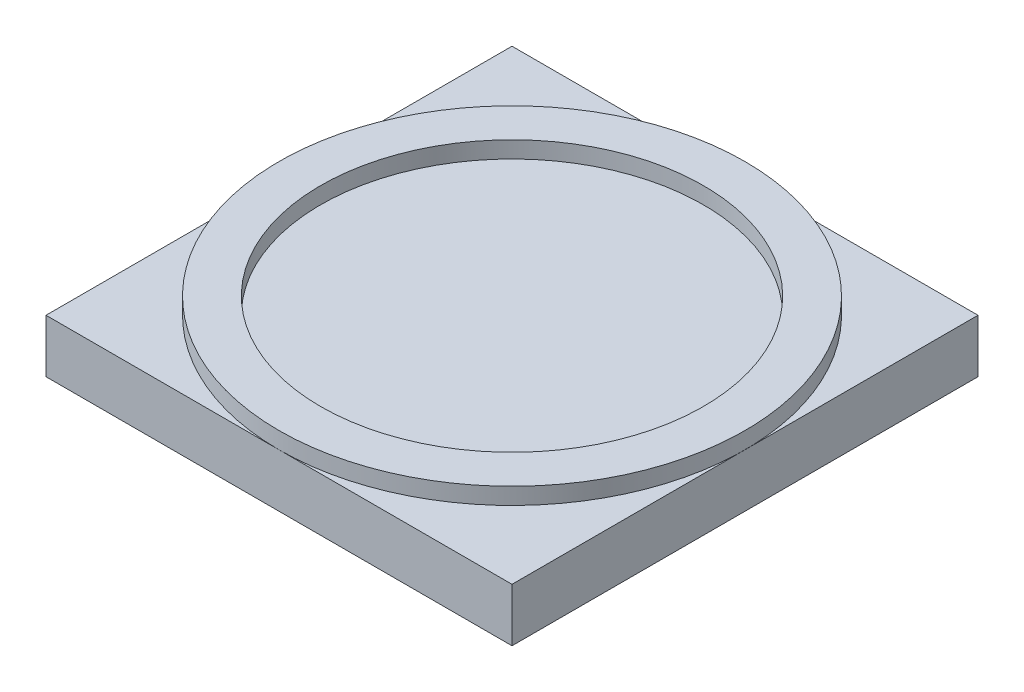
from build123d import *

# Parameters (mm, degrees)
SKETCH1_W           = 14
SKETCH1_H           = 14
BOSS_EXTRUDE1_DEPTH = 1.6
SKETCH2_R           = 7
SKETCH2_R_2         = 5.75
BOSS_EXTRUDE2_DEPTH = 0.5


with BuildPart() as part:
    # Sketch1 → Boss-Extrude1 (new body)
    with BuildSketch(Plane(origin=(0, 0, 0), x_dir=(1, 0, 0), z_dir=(0, 1, 0))):
        Rectangle(SKETCH1_W, SKETCH1_H)
    extrude(amount=BOSS_EXTRUDE1_DEPTH)


with BuildPart() as body_2:
    # Sketch2 → Boss-Extrude2 (new body)
    with BuildSketch(Plane(origin=(0, 1.6, 0), x_dir=(1, 0, 0), z_dir=(0, 1, 0))):
        Circle(SKETCH2_R)
        Circle(SKETCH2_R_2, mode=Mode.SUBTRACT)
    extrude(amount=BOSS_EXTRUDE2_DEPTH)


solid = Compound([part.part, body_2.part])
